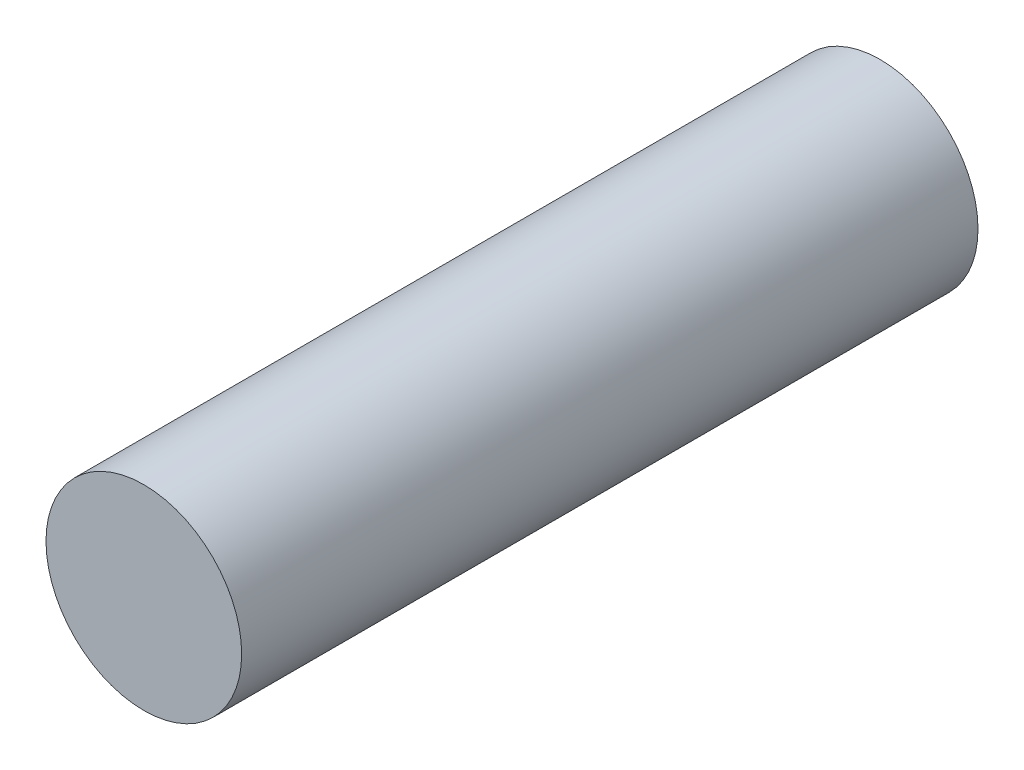
from build123d import *

# Parameters (mm, degrees)
CROQUIS1_R              = 4.65
SALIENTE_EXTRUIR1_DEPTH = 35


with BuildPart() as part:
    # Croquis1 → Saliente-Extruir1 (new body)
    with BuildSketch(Plane.XY):
        Circle(CROQUIS1_R)
    extrude(amount=SALIENTE_EXTRUIR1_DEPTH)


solid = part.part
